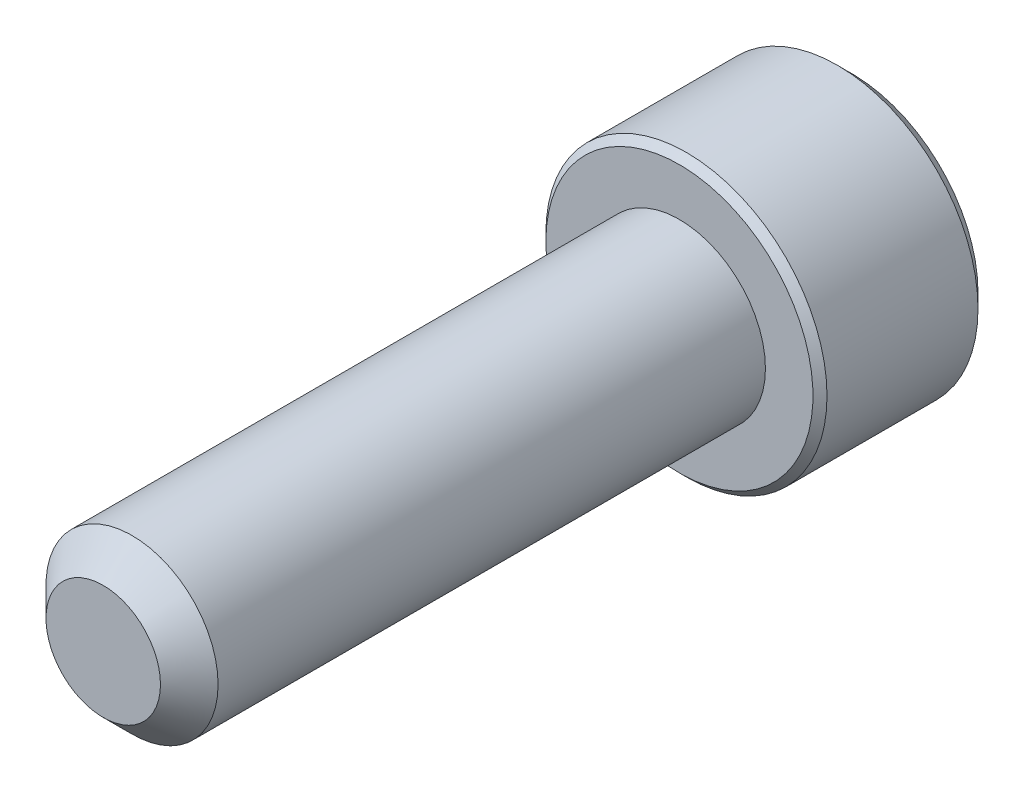
from build123d import *

# Parameters (mm, degrees)
SKETCH1_R          = 1.4224
EXTRUDE1_DEPTH     = 9.525
CHAMFER3_SIZE      = 0.47625
SKETCH6_R          = 2.3241
EXTRUDE2_DEPTH     = 2.8448
CUT_EXTRUDE1_DEPTH = 1.7859375
CHAMFER1_SIZE      = 0.23241
CHAMFER2_SIZE      = 0.116205


with BuildPart() as part:
    # Sketch1 → Extrude1 (new body)
    with BuildSketch(Plane.XY):
        Circle(SKETCH1_R)
    extrude(amount=-EXTRUDE1_DEPTH)

    # Chamfer3
    chamfer3_edges = [part.edges().sort_by_distance(p)[0] for p in [
        (-1.4224, 0, 0),
    ]]
    chamfer(chamfer3_edges, length=CHAMFER3_SIZE)

    # Sketch6 → Extrude2 (add)
    with BuildSketch(Plane(origin=(0, 0, -9.525), x_dir=(-1, 0, 0), z_dir=(0, 0, -1))):
        Circle(SKETCH6_R)
    extrude(amount=EXTRUDE2_DEPTH)

    # Sketch7 → Cut-Extrude1 (cut)
    with BuildSketch(Plane(origin=(0, 0, -12.3698), x_dir=(-1, 0, 0), z_dir=(0, 0, -1))):
        Polygon((0, 1.374815329), (-1.190625, 0.687407664), (-1.190625, -0.687407664), (0, -1.374815329), (1.190625, -0.687407664), (1.190625, 0.687407664), align=None)
    extrude(amount=-CUT_EXTRUDE1_DEPTH, mode=Mode.SUBTRACT)

    # Cut-Extrude2 cone 1 section (through the dimple's axis) → Cut-Extrude2 (revolve, cut)
    with BuildSketch(Plane(origin=(0, 0, -12.3698), x_dir=(0, 1, 0), z_dir=(1, 0, 0))):
        Polygon((0, 0), (1.374815329, 0), (0, 1.374815329), align=None)
    revolve(axis=Axis((0, 0, -12.3698), (0, 0, 1)), mode=Mode.SUBTRACT)

    # Chamfer1
    chamfer1_edges = [part.edges().sort_by_distance(p)[0] for p in [
        (2.3241, 0, -12.3698),
    ]]
    chamfer(chamfer1_edges, length=CHAMFER1_SIZE)

    # Chamfer2
    chamfer2_edges = [part.edges().sort_by_distance(p)[0] for p in [
        (2.3241, 0, -9.525),
    ]]
    chamfer(chamfer2_edges, length=CHAMFER2_SIZE)


solid = part.part
